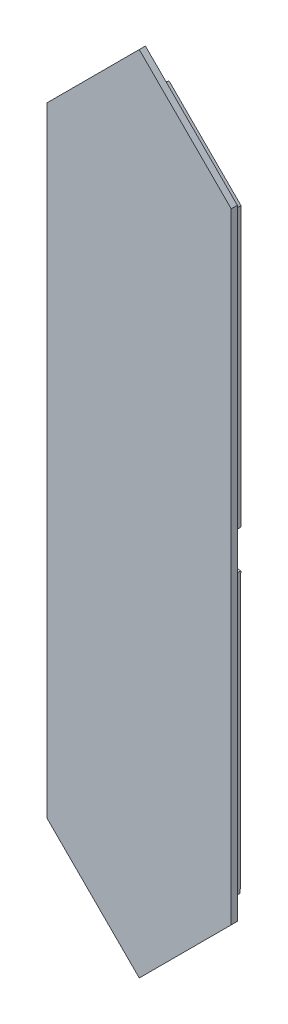
from build123d import *

# Parameters (mm, degrees)
BOSS_EXTRU_1_DEPTH = 2
BOSS_EXTRU_2_DEPTH = 1


with BuildPart() as part:
    # Esquisse1 → Boss.-Extru.1 (new body)
    with BuildSketch(Plane.XY):
        with BuildLine():
            Line((-13.186835109, -48.813164891), (-1.838477631, -60.161522369))
            ThreePointArc((-1.838477631, -60.161522369), (0, -59.4), (1.838477631, -60.161522369))
            Line((1.838477631, -60.161522369), (13.443252333, -48.599927693))
            Line((13.443252333, -48.599927693), (13.526323228, -3.099888238))
            ThreePointArc((13.526323228, -3.099888238), (10.400079466, 0.022196444), (13.570710678, 3.099193443))
            Line((13.570710678, 3.099193443), (13.570710678, 48.429289322))
            Line((13.570710678, 48.429289322), (1.838477631, 60.161522369))
            ThreePointArc((1.838477631, 60.161522369), (0, 59.4), (-1.838477631, 60.161522369))
            Line((-1.838477631, 60.161522369), (-13.103328579, 48.983053521))
            Line((-13.103328579, 48.983053521), (-13.103328579, 3.074516512))
            ThreePointArc((-13.103328579, 3.074516512), (-10.4, 0), (-13.103328579, -3.074516512))
            Line((-13.103328579, -3.074516512), (-13.186835109, -48.813164891))
        make_face()
    extrude(amount=BOSS_EXTRU_1_DEPTH)

    # Esquisse2 → Boss.-Extru.2 (add)
    with BuildSketch(Plane.XY.offset(2)):
        Polygon((0, 65.151280821), (-15.028155385, 50.123125436), (-15.028155385, -50.75260641), (0, -65.780761795), (14.971844615, -50.80891718), (14.971844615, 50.179436206), align=None)
    extrude(amount=BOSS_EXTRU_2_DEPTH)


solid = part.part
